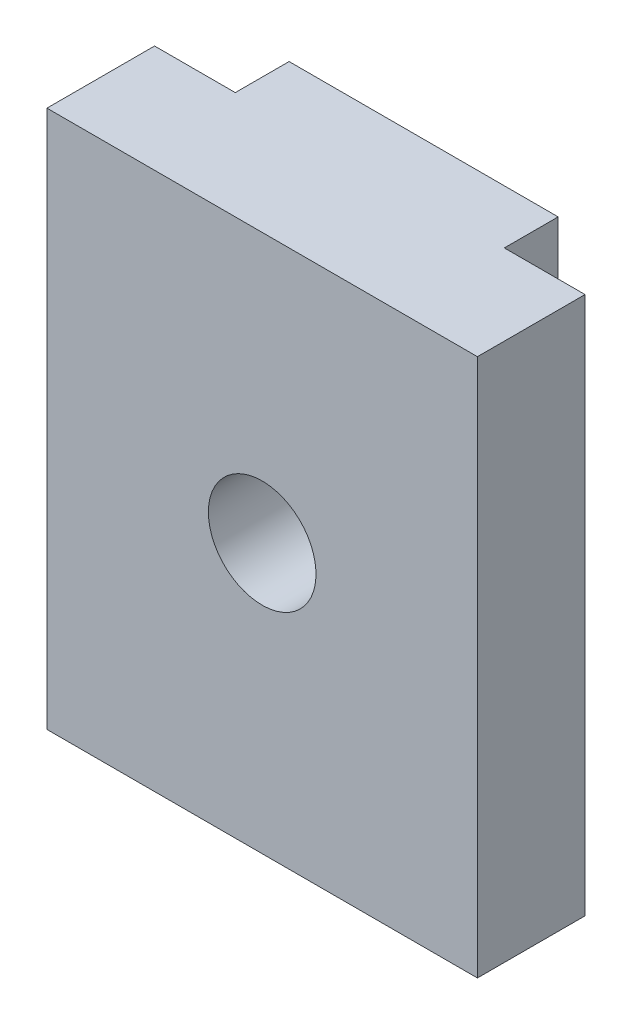
from build123d import *

# Parameters (mm, degrees)
EXTRUDE_1_DEPTH     = 20
CUT_EXTRUDE_2_DEPTH = 20


with BuildPart() as part:
    # 草图1 → 凸台-拉伸1 (new body)
    with BuildSketch(Plane(origin=(0, 0, 0), x_dir=(1, 0, 0), z_dir=(0, 1, 0))):
        Polygon((5, 2), (8, 2), (8, -2), (-8, -2), (-8, 2), (-5, 2), (-5, 4), (5, 4), align=None)
    extrude(amount=EXTRUDE_1_DEPTH)

    # 草图4 → 切除-拉伸2 (cut)
    with BuildSketch(Plane(origin=(0, 0, -4), x_dir=(-1, 0, 0), z_dir=(0, 0, -1))):
        with BuildLine():
            ThreePointArc((2, 10), (1.051462224, 11.701301617), (-0.894427191, 11.788854382))
            Line((-0.894427191, 11.788854382), (0.894427191, 8.211145618))
            ThreePointArc((0.894427191, 8.211145618), (1.701301617, 8.948537776), (2, 10))
        make_face()
        with BuildLine():
            Line((0.894427191, 8.211145618), (-0.894427191, 11.788854382))
            ThreePointArc((-0.894427191, 11.788854382), (-1.788854382, 9.105572809), (0.894427191, 8.211145618))
        make_face()
    extrude(amount=-CUT_EXTRUDE_2_DEPTH, mode=Mode.SUBTRACT)


solid = part.part
